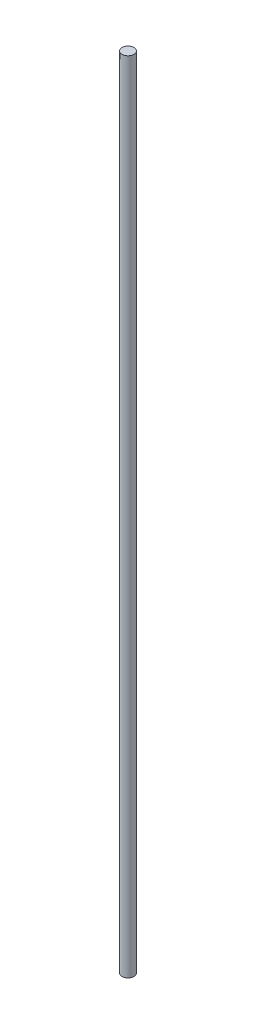
from build123d import *

# Parameters (mm, degrees)
SKETCH1_R           = 3
BOSS_EXTRUDE1_DEPTH = 400


with BuildPart() as part:
    # Sketch1 → Boss-Extrude1 (new body)
    with BuildSketch(Plane(origin=(0, 0, 0), x_dir=(1, 0, 0), z_dir=(0, 1, 0))):
        Circle(SKETCH1_R)
    extrude(amount=BOSS_EXTRUDE1_DEPTH)


solid = part.part
